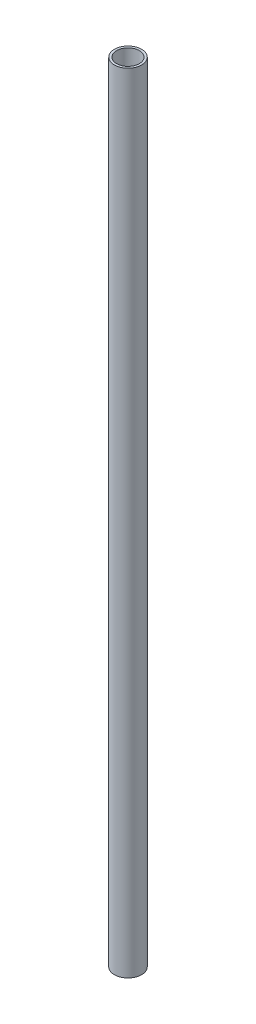
from build123d import *

# Parameters (mm, degrees)
SKETCH1_R           = 6
SKETCH1_R_2         = 5
BOSS_EXTRUDE1_DEPTH = 347


with BuildPart() as part:
    # Sketch1 → Boss-Extrude1 (new body)
    with BuildSketch(Plane(origin=(0, 0, 0), x_dir=(1, 0, 0), z_dir=(0, 1, 0))):
        Circle(SKETCH1_R)
        Circle(SKETCH1_R_2, mode=Mode.SUBTRACT)
    extrude(amount=BOSS_EXTRUDE1_DEPTH)


solid = part.part
